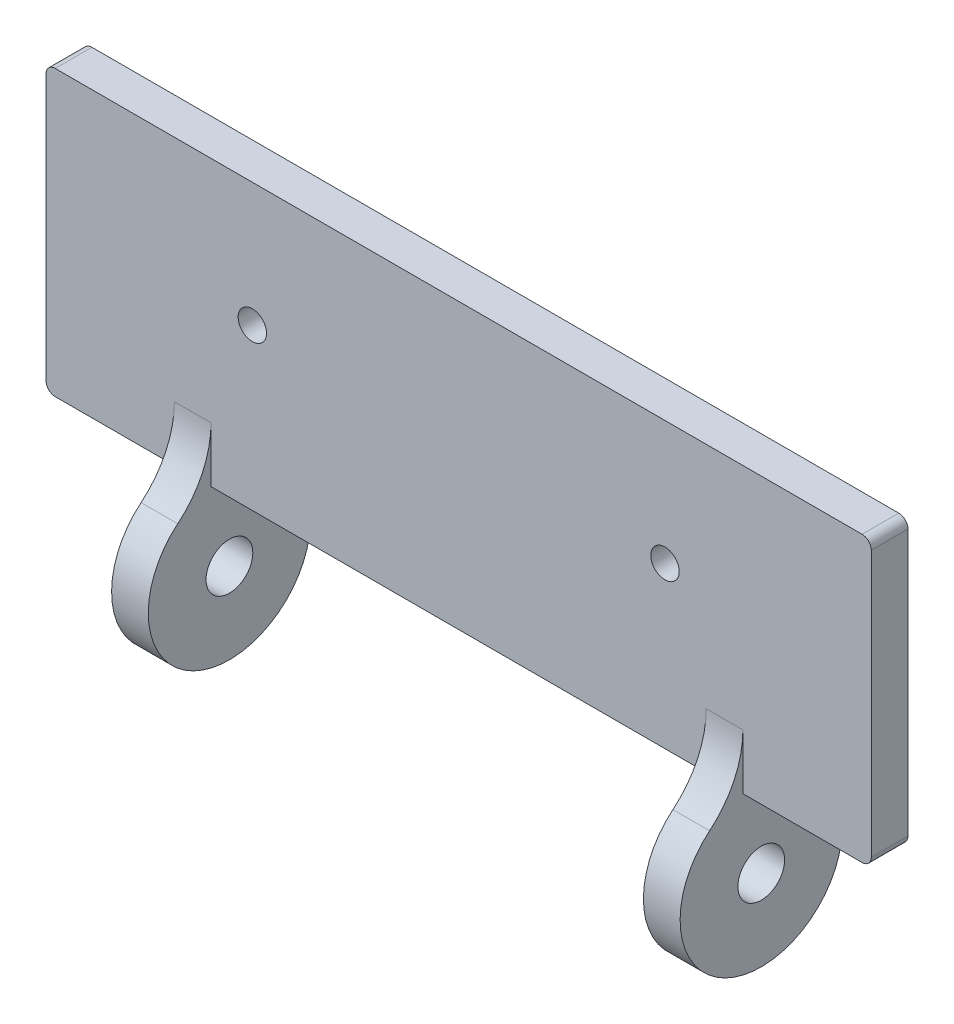
from build123d import *

# Parameters (mm, degrees)
SKIZZE1_W                       = 90
SKIZZE1_H                       = 31
AUFSATZ_LINEAR_AUSTRAGEN1_DEPTH = 4
SKIZZE4_R                       = 8.85
SKIZZE4_R_2                     = 2.55
AUFSATZ_LINEAR_AUSTRAGEN3_DEPTH = 4
LINEARES_MUSTER1_COUNT          = 2
LINEARES_MUSTER1_PITCH          = 58
VERRUNDUNG2_R                   = 10
VERRUNDUNG3_R                   = 2
SKIZZE6_R                       = 1.55
SCHNITT_LINEAR_AUSTRAGEN1_DEPTH = 4
VERRUNDUNG4_R                   = 1


with BuildPart() as part:
    # Skizze1 → Aufsatz-Linear austragen1 (new body)
    with BuildSketch(Plane.XY):
        with Locations((-4.068471812, 5.991025438)):
            Rectangle(SKIZZE1_W, SKIZZE1_H)
    extrude(amount=AUFSATZ_LINEAR_AUSTRAGEN1_DEPTH)

    # Skizze4 → Aufsatz-Linear austragen3 (add)
    with BuildSketch(Plane(origin=(26.931528188, 0, 0), x_dir=(0, 0, -1), z_dir=(1, 0, 0))):
        with Locations((-2, -18.01992615)):
            Circle(SKIZZE4_R)
        with Locations((-2, -18.01992615)):
            Circle(SKIZZE4_R_2, mode=Mode.SUBTRACT)
    aufsatz_linear_austragen3 = extrude(amount=-AUFSATZ_LINEAR_AUSTRAGEN3_DEPTH)

    # Lineares Muster1: Aufsatz-Linear austragen3 ×2
    with Locations(*[(-i * LINEARES_MUSTER1_PITCH, 0, 0) for i in range(1, LINEARES_MUSTER1_COUNT)]):
        add(aufsatz_linear_austragen3)

    # Verrundung2
    verrundung2_edges = [part.edges().sort_by_distance(p)[0] for p in [
        (24.931528188, -9.39887633, 4),
        (-33.068471812, -9.39887633, 4),
    ]]
    fillet(verrundung2_edges, radius=VERRUNDUNG2_R)

    # Verrundung3
    verrundung3_edges = [part.edges().sort_by_distance(p)[0] for p in [
        (24.931528188, -9.39887633, 0),
        (-33.068471812, -9.39887633, 0),
    ]]
    fillet(verrundung3_edges, radius=VERRUNDUNG3_R)

    # Skizze6 → Schnitt-Linear austragen1 (cut)
    with BuildSketch(Plane.XY.offset(4)):
        with Locations((-26.568471812, 7.991025438)):
            Circle(SKIZZE6_R)
        with Locations((18.431528188, 7.991025438)):
            Circle(SKIZZE6_R)
    extrude(amount=-SCHNITT_LINEAR_AUSTRAGEN1_DEPTH, mode=Mode.SUBTRACT)

    # Verrundung4
    verrundung4_edges = [part.edges().sort_by_distance(p)[0] for p in [
        (40.931528188, -9.508974562, 2),
        (-49.068471812, -9.508974562, 2),
        (-49.068471812, 21.491025438, 2),
        (40.931528188, 21.491025438, 2),
    ]]
    fillet(verrundung4_edges, radius=VERRUNDUNG4_R)


solid = part.part
